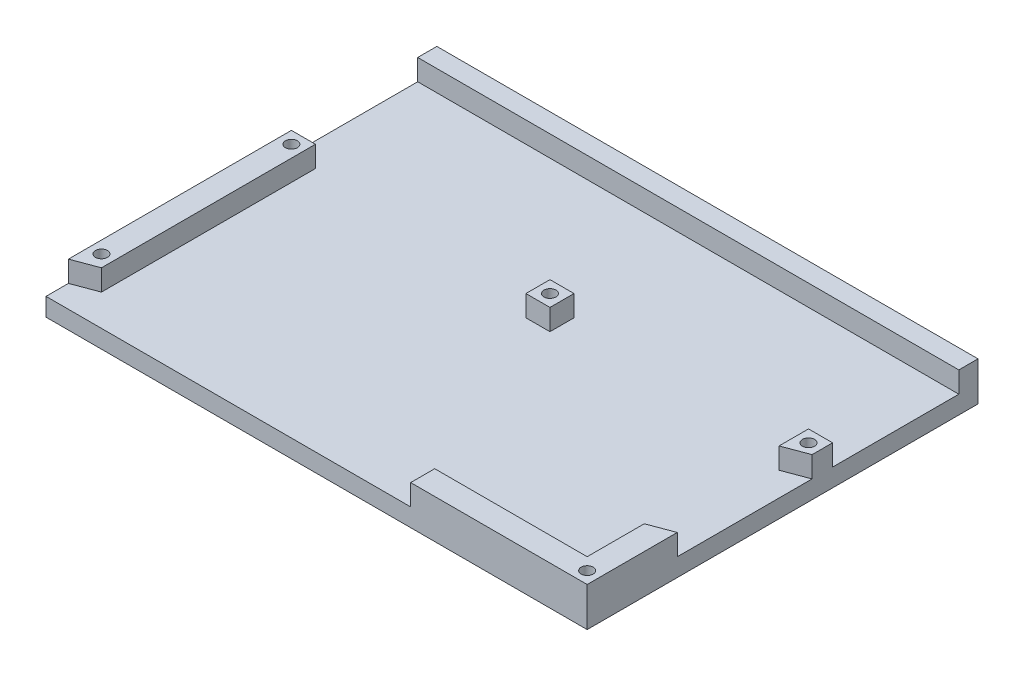
from build123d import *

# Parameters (mm, degrees)
SKETCH1_W           = 90
SKETCH1_H           = 65
BOSS_EXTRUDE1_DEPTH = 3
SKETCH2_W           = 90
SKETCH2_H           = 3.187087834
SKETCH2_W_2         = 4
SKETCH2_H_2         = 4
BOSS_EXTRUDE2_DEPTH = 3.5
SKETCH3_R           = 1
CUT_EXTRUDE1_DEPTH  = 14.5


with BuildPart() as part:
    # Sketch1 → Boss-Extrude1 (new body)
    with BuildSketch(Plane(origin=(0, 0, 0), x_dir=(1, 0, 0), z_dir=(0, 1, 0))):
        with Locations((45, 32.5)):
            Rectangle(SKETCH1_W, SKETCH1_H)
    extrude(amount=BOSS_EXTRUDE1_DEPTH)

    # Sketch2 → Boss-Extrude2 (add)
    with BuildSketch(Plane(origin=(0, 3, 0), x_dir=(1, 0, 0), z_dir=(0, 1, 0))):
        with Locations((45, 63.406456083)):
            Rectangle(SKETCH2_W, SKETCH2_H)
        Polygon((4, 40.812912166), (0, 40.812912166), (0, 3.72632866), (4, 5.223282533), align=None)
        with Locations((45, 38.812912166)):
            Rectangle(SKETCH2_W_2, SKETCH2_H_2)
        Polygon((90, 4), (90, 14.985391195), (86, 13.488437322), (86, 4), (60.646012831, 4), (60.646012831, 0), (90, 0), align=None)
        Polygon((90, 37.407790801), (90, 40.812912166), (86, 40.812912166), (86, 35.910836928), align=None)
    extrude(amount=BOSS_EXTRUDE2_DEPTH)

    # Sketch3 → Cut-Extrude1 (cut)
    with BuildSketch(Plane(origin=(0, 6.5, 0), x_dir=(1, 0, 0), z_dir=(0, 1, 0))):
        with Locations((2, 38.812912166)):
            Circle(SKETCH3_R)
        with Locations((45, 38.812912166)):
            Circle(SKETCH3_R)
        with Locations((88, 38.812912166)):
            Circle(SKETCH3_R)
        with Locations((88, 2)):
            Circle(SKETCH3_R)
        with Locations((2, 7.223282533)):
            Circle(SKETCH3_R)
    extrude(amount=-CUT_EXTRUDE1_DEPTH, mode=Mode.SUBTRACT)


solid = part.part
